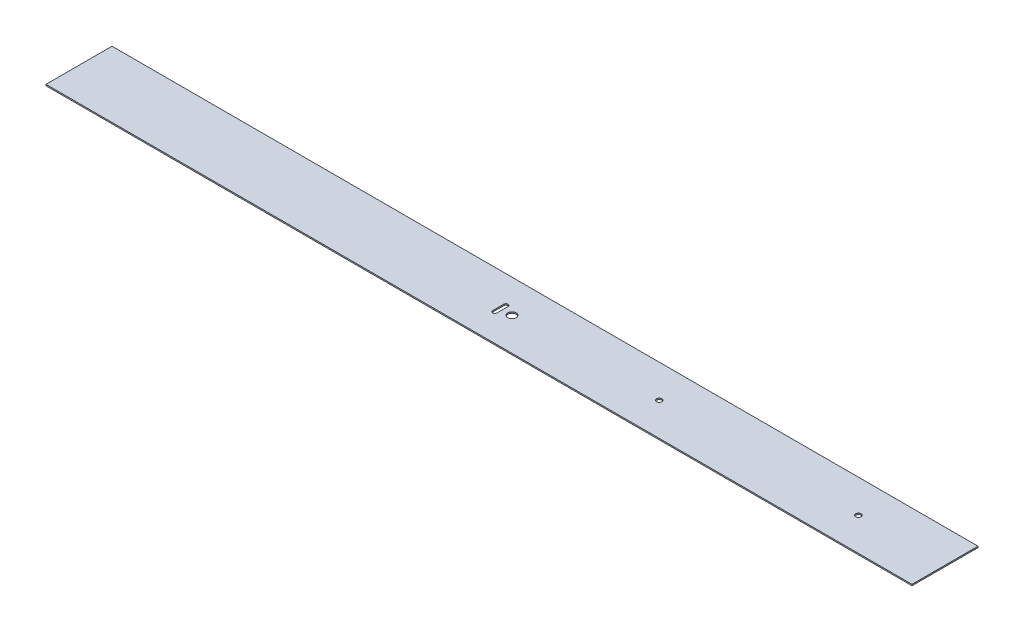
from build123d import *

# Parameters (mm, degrees)
SKETCH1_W           = 1000
SKETCH1_H           = 76.2
SKETCH1_R           = 4.83
BOSS_EXTRUDE1_DEPTH = 0.75
SKETCH2_R           = 2.98
SKETCH2_R_2         = 3.11
CUT_EXTRUDE1_DEPTH  = 2.5


with BuildPart() as part:
    # Sketch1 → Boss-Extrude1 (new body, symmetric)
    with BuildSketch(Plane(origin=(0, 0, 0), x_dir=(1, 0, 0), z_dir=(0, 1, 0))):
        Rectangle(SKETCH1_W, SKETCH1_H)
        Circle(SKETCH1_R, mode=Mode.SUBTRACT)
        with BuildLine():
            Line((-15.8, -6.35), (-15.8, 6.35))
            ThreePointArc((-15.8, 6.35), (-13.4, 8.75), (-11, 6.35))
            Line((-11, 6.35), (-11, -6.35))
            ThreePointArc((-11, -6.35), (-13.4, -8.75), (-15.8, -6.35))
        make_face(mode=Mode.SUBTRACT)
    extrude(amount=BOSS_EXTRUDE1_DEPTH, both=True)

    # Sketch2 → Cut-Extrude1 (cut, through all)
    with BuildSketch(Plane(origin=(0, 0.75, 0), x_dir=(1, 0, 0), z_dir=(0, 1, 0))):
        with Locations((170, 0)):
            Circle(SKETCH2_R)
        with Locations((400, 0)):
            Circle(SKETCH2_R_2)
    extrude(amount=-CUT_EXTRUDE1_DEPTH, mode=Mode.SUBTRACT)


solid = part.part
